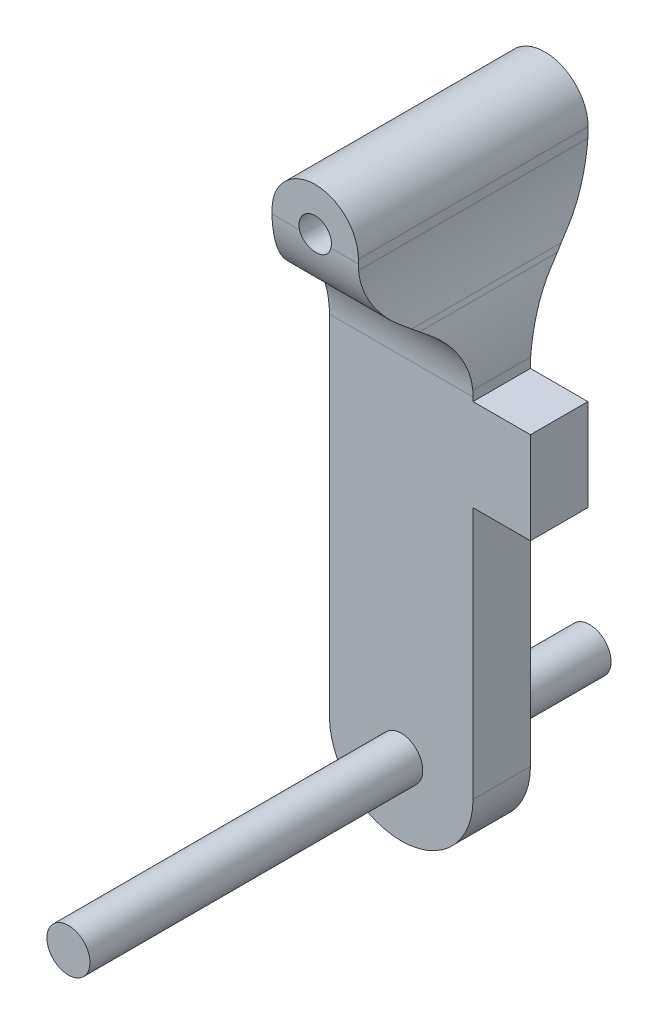
from build123d import *

# Parameters (mm, degrees)
SKETCH1_W           = 22.225
SKETCH1_H           = 67.6402
BOSS_EXTRUDE1_DEPTH = 25.4
SKETCH2_R           = 1.7907
CUT_EXTRUDE2_DEPTH  = 25.4
SKETCH4_W           = 9.525
SKETCH4_H           = 10.16
SKETCH4_H_2         = 35.894850391
SKETCH4_H_3         = 35.916644849
CUT_EXTRUDE3_DEPTH  = 51.712797865
BOSS_EXTRUDE2_START = -43.154689
SKETCH5_R           = 2.38125
BOSS_EXTRUDE2_DEPTH = 57.632689


with BuildPart() as part:
    # Sketch1 → Boss-Extrude1 (new body)
    with BuildSketch(Plane.XY):
        with Locations((-17.147623967, 4.03062314)):
            Rectangle(SKETCH1_W, SKETCH1_H)
    extrude(amount=BOSS_EXTRUDE1_DEPTH)

    # Sketch2 → Cut-Extrude2 (cut)
    with BuildSketch(Plane.XY.offset(25.4)):
        with BuildLine():
            ThreePointArc((-20.309923967, 37.85072314), (-16.933347665, 36.452099442), (-15.534723967, 33.07552314))
            Line((-15.534723967, 33.07552314), (-15.534723967, 31.988846816))
            ThreePointArc((-15.534723967, 31.988846816), (-15.164047916, 28.377221194), (-14.067475414, 24.916185349))
            Line((-14.067475414, 24.916185349), (-13.85237252, 24.420060932))
            ThreePointArc((-13.85237252, 24.420060932), (-12.755800018, 20.959025087), (-12.385123967, 17.347399465))
            Line((-12.385123967, 17.347399465), (-12.385123967, 16.26072314))
            Line((-12.385123967, 16.26072314), (-6.035123967, 16.26072314))
            Line((-6.035123967, 16.26072314), (-6.035123967, 37.85072314))
            Line((-6.035123967, 37.85072314), (-20.309923967, 37.85072314))
        make_face()
        with BuildLine():
            Line((-25.085123967, 32.016111722), (-25.085123967, 33.07552314))
            ThreePointArc((-25.085123967, 33.07552314), (-23.686500268, 36.452099442), (-20.309923967, 37.85072314))
            Line((-20.309923967, 37.85072314), (-28.260123967, 37.85072314))
            Line((-28.260123967, 37.85072314), (-28.260123967, 17.320134559))
            ThreePointArc((-28.260123967, 17.320134559), (-27.884120973, 20.957343409), (-26.772015056, 24.440716329))
            Line((-26.772015056, 24.440716329), (-26.573232878, 24.895529952))
            ThreePointArc((-26.573232878, 24.895529952), (-25.461126961, 28.378902872), (-25.085123967, 32.016111722))
        make_face()
        with BuildLine():
            Line((-6.035123967, -29.78947686), (-6.035123967, 6.10072314))
            Line((-6.035123967, 6.10072314), (-12.385123967, 6.10072314))
            Line((-12.385123967, 6.10072314), (-12.385123967, -21.85197686))
            ThreePointArc((-12.385123967, -21.85197686), (-14.709963891, -27.464636935), (-20.322623967, -29.78947686))
            Line((-20.322623967, -29.78947686), (-6.035123967, -29.78947686))
        make_face()
        with BuildLine():
            ThreePointArc((-20.322623967, -29.78947686), (-25.935284043, -27.464636935), (-28.260123967, -21.85197686))
            Line((-28.260123967, -21.85197686), (-28.260123967, -29.78947686))
            Line((-28.260123967, -29.78947686), (-20.322623967, -29.78947686))
        make_face()
        with Locations((-20.309923967, 33.07552314)):
            Circle(SKETCH2_R)
    extrude(amount=-CUT_EXTRUDE2_DEPTH, mode=Mode.SUBTRACT)

    # Sketch4 → Cut-Extrude3 (cut, through all)
    with BuildSketch(Plane(origin=(-6.035123967, 0, 0), x_dir=(0, 0, -1), z_dir=(1, 0, 0))):
        with BuildLine():
            Line((-9.525, 16.698464592), (-9.525, 16.26072314))
            Line((-9.525, 16.26072314), (0, 16.26072314))
            Line((0, 16.26072314), (0, 32.637781689))
            ThreePointArc((0, 32.637781689), (-0.909409772, 28.750457477), (-3.448884978, 25.669973531))
            Line((-3.448884978, 25.669973531), (-6.076115022, 23.66627275))
            ThreePointArc((-6.076115022, 23.66627275), (-8.615590228, 20.585788804), (-9.525, 16.698464592))
        make_face()
        with Locations((-4.7625, 11.18072314)):
            Rectangle(SKETCH4_W, SKETCH4_H)
        with Locations((-4.7625, -11.846702056)):
            Rectangle(SKETCH4_W, SKETCH4_H_2)
        with Locations((-20.6375, -11.857599285)):
            Rectangle(SKETCH4_W, SKETCH4_H_3)
        with Locations((-20.6375, 11.18072314)):
            Rectangle(SKETCH4_W, SKETCH4_H)
        with BuildLine():
            Line((-25.4, 16.26072314), (-15.875, 16.26072314))
            Line((-15.875, 16.26072314), (-15.875, 16.698464592))
            ThreePointArc((-15.875, 16.698464592), (-16.784409772, 20.585788804), (-19.323884978, 23.66627275))
            Line((-19.323884978, 23.66627275), (-21.951115022, 25.669973531))
            ThreePointArc((-21.951115022, 25.669973531), (-24.490590228, 28.750457477), (-25.4, 32.637781689))
            Line((-25.4, 32.637781689), (-25.4, 16.26072314))
        make_face()
    extrude(amount=-CUT_EXTRUDE3_DEPTH, mode=Mode.SUBTRACT)

    # Sketch5 → Boss-Extrude2 (add)
    with BuildSketch(Plane(origin=(0, 0, 9.525), x_dir=(-1, 0, 0), z_dir=(0, 0, -1)).offset(BOSS_EXTRUDE2_START)):
        with Locations((20.322623967, -21.85197686)):
            Circle(SKETCH5_R)
    extrude(amount=BOSS_EXTRUDE2_DEPTH)


solid = part.part
